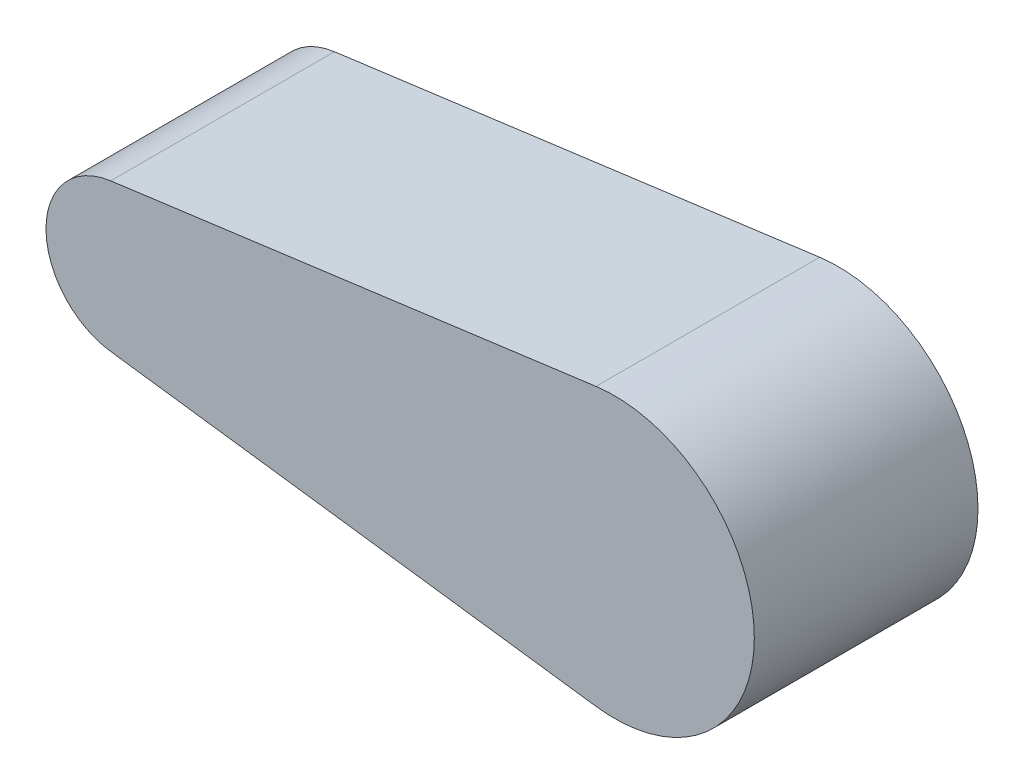
from build123d import *

# Parameters (mm, degrees)
EXTRUDE1_DEPTH = 120


with BuildPart() as part:
    # Sketch1 → Extrude1 (new body)
    with BuildSketch(Plane.XY):
        with BuildLine():
            Line((-155.283018868, 39.649586525), (105.094339623, 74.342974735))
            ThreePointArc((105.094339623, 74.342974735), (189.99999998, -0.001728761), (105.090912401, -74.342518003))
            Line((105.090912401, -74.342518003), (-154.307692308, -39.767370883))
            ThreePointArc((-154.307692308, -39.767370883), (-189.996983839, -0.491206437), (-155.283018868, 39.649586525))
        make_face()
    extrude(amount=EXTRUDE1_DEPTH)


solid = part.part
